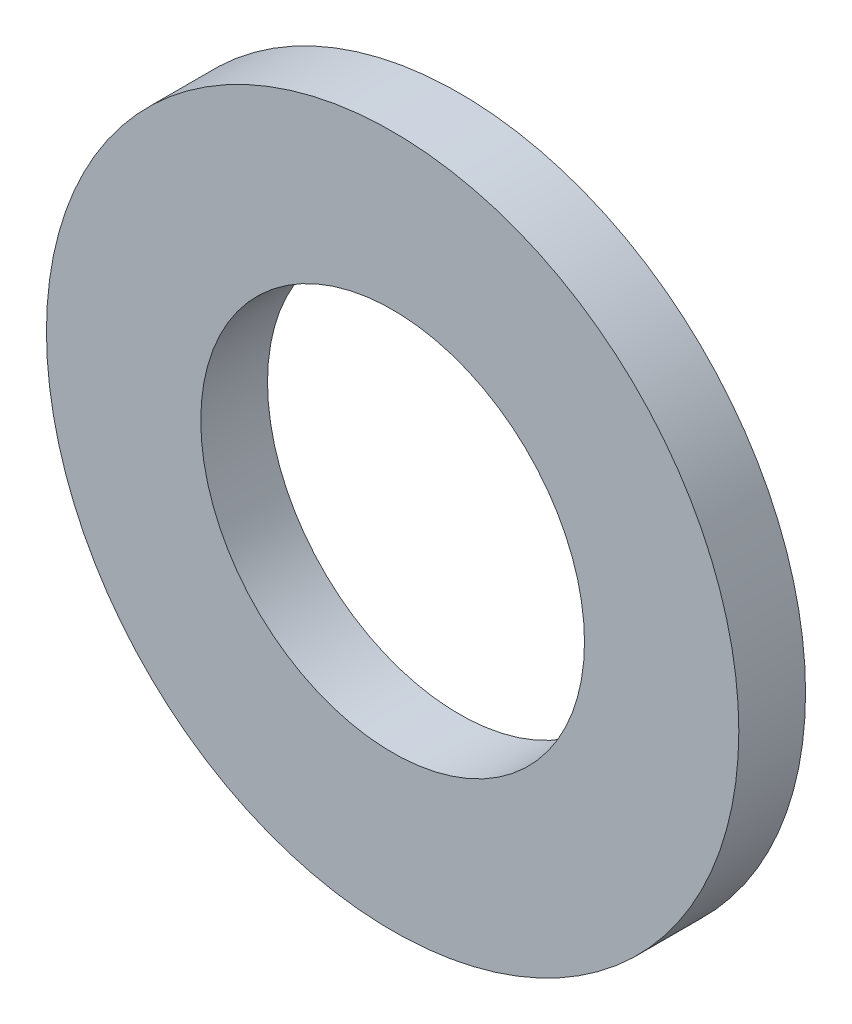
from build123d import *

# Parameters (mm, degrees)
SKETCH1_R           = 8.3
SKETCH1_R_2         = 4.6
BOSS_EXTRUDE1_DEPTH = 1.6


with BuildPart() as part:
    # Sketch1 → Boss-Extrude1 (new body)
    with BuildSketch(Plane.XY):
        Circle(SKETCH1_R)
        Circle(SKETCH1_R_2, mode=Mode.SUBTRACT)
    extrude(amount=BOSS_EXTRUDE1_DEPTH)


solid = part.part
